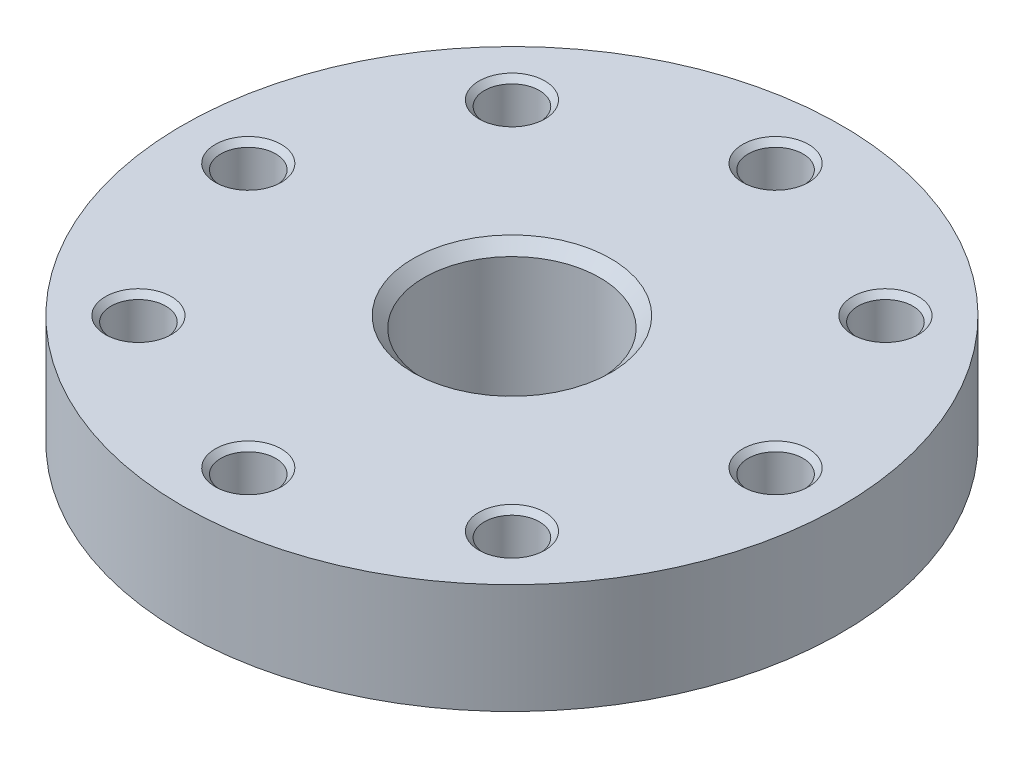
from build123d import *

# Parameters (mm, degrees)
SKETCH1_R           = 15
BOSS_EXTRUDE1_DEPTH = 5
SKETCH2_R           = 1.25
CUT_EXTRUDE1_DEPTH  = 6
SKETCH3_R           = 6
BOSS_EXTRUDE2_DEPTH = 1.5
SKETCH4_R           = 1.5
CUT_EXTRUDE2_DEPTH  = 1.5
CHAMFER5_SIZE       = 0.25
SKETCH5_R           = 4
CUT_EXTRUDE3_DEPTH  = 6
CHAMFER7_SIZE       = 0.5


with BuildPart() as part:
    # Sketch1 → Boss-Extrude1 (new body)
    with BuildSketch(Plane(origin=(0, 0, 0), x_dir=(1, 0, 0), z_dir=(0, 1, 0))):
        Circle(SKETCH1_R)
    extrude(amount=BOSS_EXTRUDE1_DEPTH)

    # Sketch2 → Cut-Extrude1 (cut, through all)
    with BuildSketch(Plane(origin=(0, 5, 0), x_dir=(1, 0, 0), z_dir=(0, 1, 0))):
        with Locations((0, 12)):
            Circle(SKETCH2_R)
        with Locations((-12, 0)):
            Circle(SKETCH2_R)
        with Locations((0, -12)):
            Circle(SKETCH2_R)
        with Locations((12, 0)):
            Circle(SKETCH2_R)
        with Locations((-8.5, 8.5)):
            Circle(SKETCH2_R)
        with Locations((-8.5, -8.5)):
            Circle(SKETCH2_R)
        with Locations((8.5, 8.5)):
            Circle(SKETCH2_R)
        with Locations((8.5, -8.5)):
            Circle(SKETCH2_R)
    extrude(amount=-CUT_EXTRUDE1_DEPTH, mode=Mode.SUBTRACT)

    # Sketch3 → Boss-Extrude2 (add)
    with BuildSketch(Plane(origin=(0, 0, 0), x_dir=(1, 0, 0), z_dir=(0, 1, 0))):
        Circle(SKETCH3_R)
    extrude(amount=-BOSS_EXTRUDE2_DEPTH)

    # Sketch4 → Cut-Extrude2 (cut)
    with BuildSketch(Plane.XZ.offset(1.5)):
        Circle(SKETCH4_R)
    extrude(amount=-CUT_EXTRUDE2_DEPTH, mode=Mode.SUBTRACT)

    # Chamfer5
    chamfer5_edges = [part.edges().sort_by_distance(p)[0] for p in [
        (-1.25, 0, -12),
        (-1.25, 5, -12),
        (7.25, 0, 8.5),
        (7.25, 5, 8.5),
        (7.25, 0, -8.5),
        (7.25, 5, -8.5),
        (-9.75, 0, -8.5),
        (-9.75, 5, -8.5),
        (-13.25, 0, 0),
        (-13.25, 5, 0),
        (-1.25, 0, 12),
        (-1.25, 5, 12),
        (10.75, 0, 0),
        (10.75, 5, 0),
        (-9.75, 0, 8.5),
        (-9.75, 5, 8.5),
    ]]
    chamfer(chamfer5_edges, length=CHAMFER5_SIZE)

    # Sketch5 → Cut-Extrude3 (cut)
    with BuildSketch(Plane(origin=(0, 5, 0), x_dir=(1, 0, 0), z_dir=(0, 1, 0))):
        Circle(SKETCH5_R)
    extrude(amount=-CUT_EXTRUDE3_DEPTH, mode=Mode.SUBTRACT)

    # Chamfer7
    chamfer7_edges = [part.edges().sort_by_distance(p)[0] for p in [
        (-4, 5, 0),
    ]]
    chamfer(chamfer7_edges, length=CHAMFER7_SIZE)


solid = part.part
